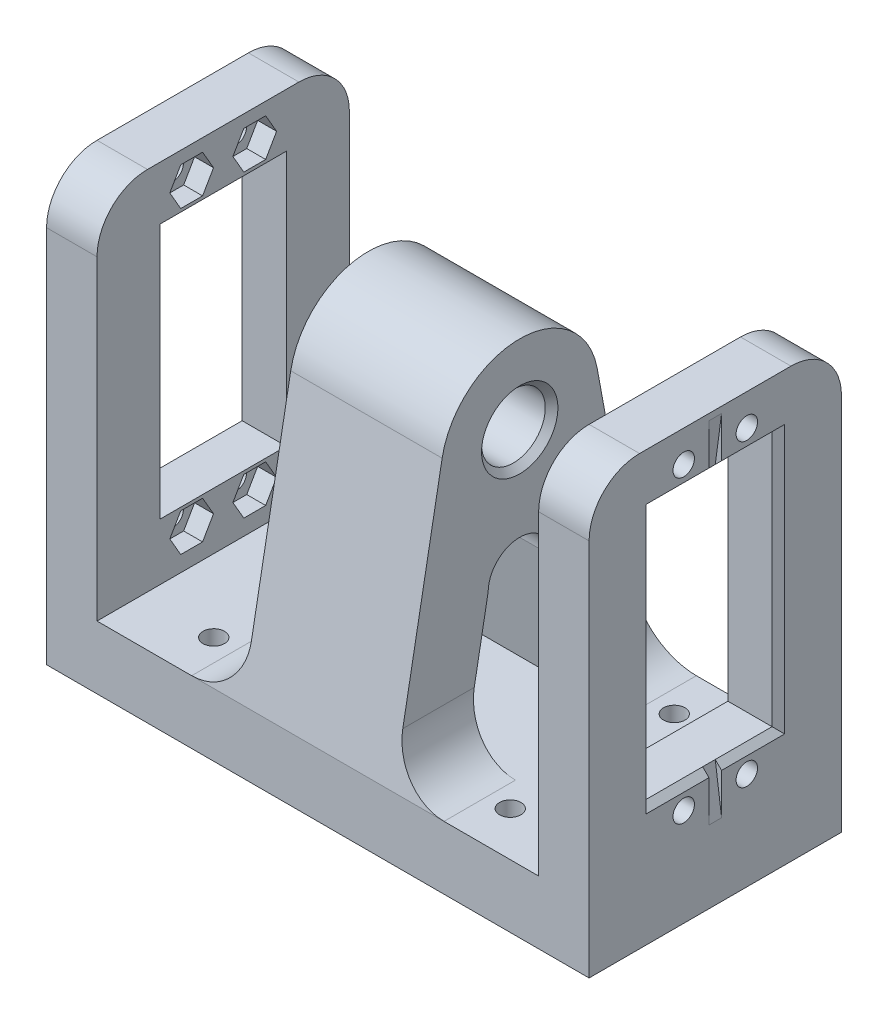
from build123d import *

# Parameters (mm, degrees)
SKETCH_1_W             = 8
SKETCH_1_H             = 58
SKETCH_1_W_2           = 12
EXTRUDE_1_DEPTH        = 20
SKETCH_3_R             = 1.7
SKETCH_3_W             = 20
SKETCH_3_H             = 40.5
CUT_EXTRUDE_1575_DEPTH = 8
SKETCH_2_R             = 5.05
CUT_EXTRUDE_2513_DEPTH = 12
CUT_EXTRUDE_2852_DEPTH = 1
SKETCH_5_R             = 1.7
CUT_EXTRUDE_3257_DEPTH = 3
SKETCH_6_R             = 1.7
CUT_EXTRUDE_5_DEPTH    = 10
FILLET_1_R             = 8
CHAMFER_1_SIZE         = 1


with BuildPart() as part:
    # Эскиз1 → Бобышка-Вытянуть1 (new body, symmetric)
    with BuildSketch(Plane.XY):
        Polygon((0, -10), (0, 0), (-12, 0), (-35, 0), (-43, 0), (-43, -10), align=None)
        with Locations((-39, 29)):
            Rectangle(SKETCH_1_W, SKETCH_1_H)
        with Locations((-6, 29)):
            Rectangle(SKETCH_1_W_2, SKETCH_1_H)
    extrude(amount=EXTRUDE_1_DEPTH, both=True)

    # Эскиз3 → Cut-Extrude 1575 (cut)
    with BuildSketch(Plane.ZY.offset(43)):
        with Locations((-5, 53)):
            Circle(SKETCH_3_R)
        with Locations((5, 53)):
            Circle(SKETCH_3_R)
        with Locations((-5, 5.5)):
            Circle(SKETCH_3_R)
        with Locations((5, 5.5)):
            Circle(SKETCH_3_R)
        with Locations((0, 29.25)):
            Rectangle(SKETCH_3_W, SKETCH_3_H)
    extrude(amount=-CUT_EXTRUDE_1575_DEPTH, mode=Mode.SUBTRACT)

    # Эскиз2 → Cut-Extrude 2513 (cut)
    with BuildSketch(Plane.ZY.offset(12)):
        with BuildLine():
            Line((-20, 58), (-20, 0))
            Line((-20, 0), (-12.294865589, 42.005278284))
            ThreePointArc((-12.294865589, 42.005278284), (0, 52.25), (12.294865589, 42.005278284))
            Line((12.294865589, 42.005278284), (20, 0))
            Line((20, 0), (20, 58))
            Line((20, 58), (-20, 58))
        make_face()
        with BuildLine():
            Line((-5, 20), (-8.668650572, 0))
            Line((-8.668650572, 0), (8.668650572, 0))
            Line((8.668650572, 0), (5, 20))
            ThreePointArc((5, 20), (0, 25), (-5, 20))
        make_face()
        with Locations((0, 39.75)):
            Circle(SKETCH_2_R)
    extrude(amount=-CUT_EXTRUDE_2513_DEPTH, mode=Mode.SUBTRACT)

    # Эскиз4 → Cut-Extrude 2852 (cut, symmetric)
    with BuildSketch(Plane.XY):
        Polygon((-42, 49.5), (-43, 49.5), (-43, 57), align=None)
        Polygon((-43, 9), (-43, 1.5), (-42, 9), align=None)
    extrude(amount=CUT_EXTRUDE_2852_DEPTH, both=True, mode=Mode.SUBTRACT)

    # Эскиз5 → Cut-Extrude 3257 (cut)
    with BuildSketch(Plane(origin=(-35, 0, 0), x_dir=(0, 0, -1), z_dir=(1, 0, 0))):
        Polygon((-6.732050808, 56), (-8.464101615, 53), (-6.732050808, 50), (-3.267949192, 50), (-1.535898385, 53), (-3.267949192, 56), align=None)
        with Locations((-5, 53)):
            Circle(SKETCH_5_R, mode=Mode.SUBTRACT)
        Polygon((1.535898385, 53), (3.267949192, 50), (6.732050808, 50), (8.464101615, 53), (6.732050808, 56), (3.267949192, 56), align=None)
        with Locations((5, 53)):
            Circle(SKETCH_5_R, mode=Mode.SUBTRACT)
        Polygon((-6.732050808, 8.5), (-8.464101615, 5.5), (-6.732050808, 2.5), (-3.267949192, 2.5), (-1.535898385, 5.5), (-3.267949192, 8.5), align=None)
        with Locations((-5, 5.5)):
            Circle(SKETCH_5_R, mode=Mode.SUBTRACT)
        Polygon((1.535898385, 5.5), (3.267949192, 2.5), (6.732050808, 2.5), (8.464101615, 5.5), (6.732050808, 8.5), (3.267949192, 8.5), align=None)
        with Locations((5, 5.5)):
            Circle(SKETCH_5_R, mode=Mode.SUBTRACT)
    extrude(amount=-CUT_EXTRUDE_3257_DEPTH, mode=Mode.SUBTRACT)

    # Эскиз6 → Вырез-Вытянуть5 (cut)
    with BuildSketch(Plane(origin=(0, 0, 0), x_dir=(1, 0, 0), z_dir=(0, 1, 0))):
        with Locations((-23.5, 13)):
            Circle(SKETCH_6_R)
        with Locations((-23.5, -13)):
            Circle(SKETCH_6_R)
    extrude(amount=-CUT_EXTRUDE_5_DEPTH, mode=Mode.SUBTRACT)

    # Скругление1
    fillet_1_edges = [part.edges().sort_by_distance(p)[0] for p in [
        (-39, 58, -20),
        (-12, 0, 14.334325286),
        (-39, 58, 20),
        (-12, 0, -14.334325286),
    ]]
    fillet(fillet_1_edges, radius=FILLET_1_R)

    # Фаска1
    chamfer_1_edges = [part.edges().sort_by_distance(p)[0] for p in [
        (-12, 39.75, -5.05),
        (-43, 9, 5.5),
        (-43, 49.5, 5.5),
        (-43, 29.25, 10),
        (-43, 9, -5.5),
        (-43, 49.5, -5.5),
        (-43, 29.25, -10),
    ]]
    chamfer(chamfer_1_edges, length=CHAMFER_1_SIZE)

    # Зеркальное отражение2: part across face


with BuildPart() as part_1:
    add(part.part)
    add(part.part.mirror(Plane(origin=(0, 17.029159437, 0), x_dir=(0, 0, 1), z_dir=(1, 0, 0))))


solid = part_1.part
